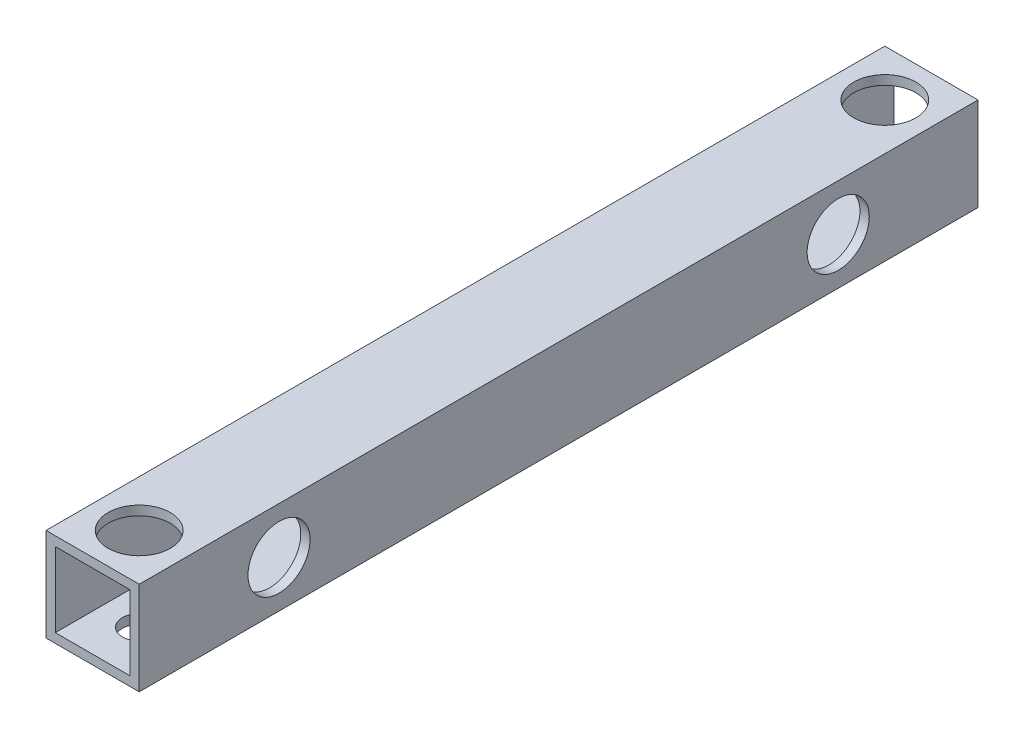
from build123d import *

# Parameters (mm, degrees)
SKETCH_1_W          = 15
SKETCH_1_H          = 15
SKETCH_1_W_2        = 12
SKETCH_1_H_2        = 12
EXTRUDE_1_DEPTH     = 135
SKETCH_2_R          = 2.7
CUT_EXTRUDE_1_DEPTH = 25
SKETCH_3_R          = 2.7
CUT_EXTRUDE_2_DEPTH = 25
SKETCH_4_R          = 5
CUT_EXTRUDE_3_DEPTH = 10
SKETCH_5_R          = 5
CUT_EXTRUDE_4_DEPTH = 10


with BuildPart() as part:
    # ｽｹｯﾁ1 → ﾎﾞｽ - 押し出し1 (new body)
    with BuildSketch(Plane.XY):
        Rectangle(SKETCH_1_W, SKETCH_1_H)
        Rectangle(SKETCH_1_W_2, SKETCH_1_H_2, mode=Mode.SUBTRACT)
    extrude(amount=EXTRUDE_1_DEPTH)

    # ｽｹｯﾁ2 → ｶｯﾄ - 押し出し1 (cut)
    with BuildSketch(Plane(origin=(7.5, 0, 0), x_dir=(0, 0, -1), z_dir=(1, 0, 0))):
        with Locations((-112.5, 0)):
            Circle(SKETCH_2_R)
        with Locations((-22.5, 0)):
            Circle(SKETCH_2_R)
    extrude(amount=-CUT_EXTRUDE_1_DEPTH, mode=Mode.SUBTRACT)

    # ｽｹｯﾁ3 → ｶｯﾄ - 押し出し2 (cut)
    with BuildSketch(Plane(origin=(0, 7.5, 0), x_dir=(1, 0, 0), z_dir=(0, 1, 0))):
        with Locations((0, -7.5)):
            Circle(SKETCH_3_R)
        with Locations((0, -127.5)):
            Circle(SKETCH_3_R)
    extrude(amount=-CUT_EXTRUDE_2_DEPTH, mode=Mode.SUBTRACT)

    # ｽｹｯﾁ4 → ｶｯﾄ - 押し出し3 (cut)
    with BuildSketch(Plane(origin=(0, 7.5, 0), x_dir=(1, 0, 0), z_dir=(0, 1, 0))):
        with Locations((0, -127.5)):
            Circle(SKETCH_4_R)
        with Locations((0, -7.5)):
            Circle(SKETCH_4_R)
    extrude(amount=-CUT_EXTRUDE_3_DEPTH, mode=Mode.SUBTRACT)

    # ｽｹｯﾁ5 → ｶｯﾄ - 押し出し4 (cut)
    with BuildSketch(Plane(origin=(7.5, 0, 0), x_dir=(0, 0, -1), z_dir=(1, 0, 0))):
        with Locations((-22.5, 0)):
            Circle(SKETCH_5_R)
        with Locations((-112.5, 0)):
            Circle(SKETCH_5_R)
    extrude(amount=-CUT_EXTRUDE_4_DEPTH, mode=Mode.SUBTRACT)


solid = part.part
